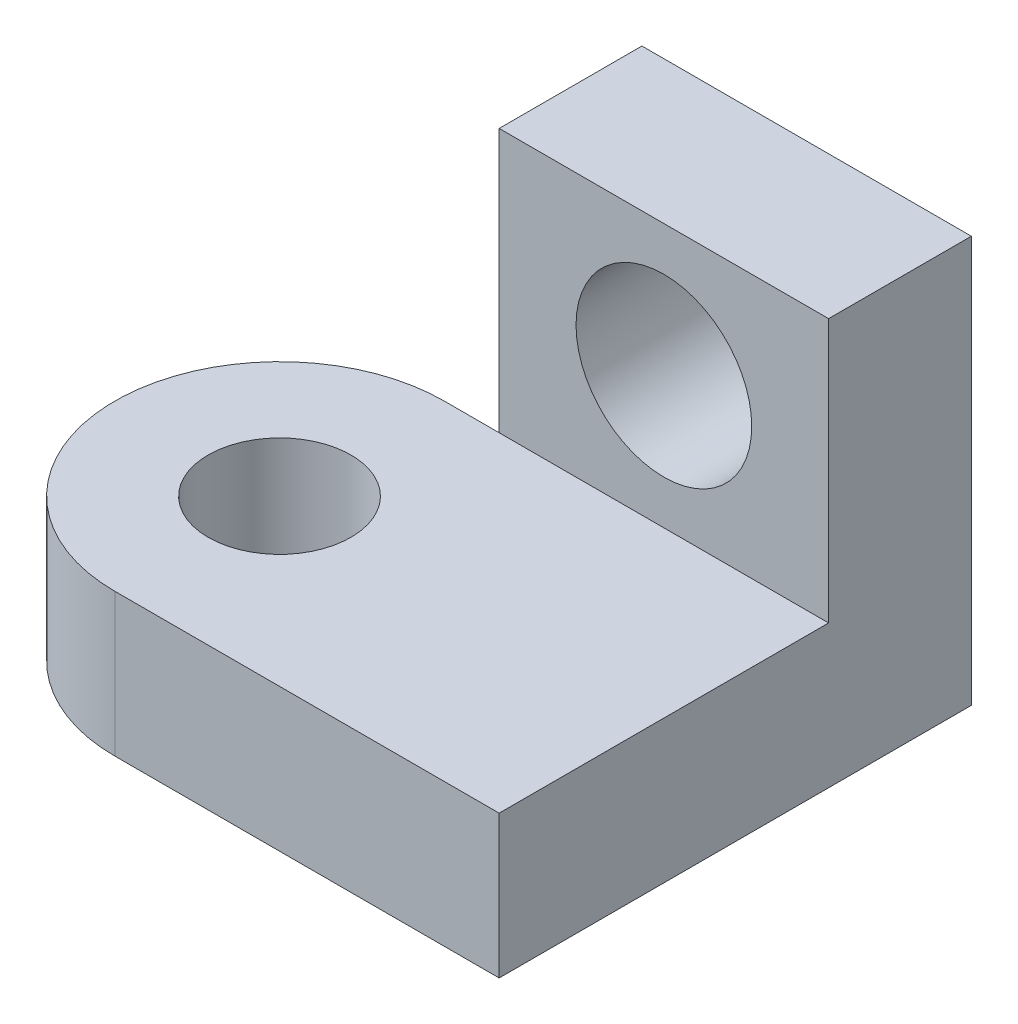
from build123d import *

# Parameters (mm, degrees)
SKETCH1_R           = 6.5
BOSS_EXTRUDE1_DEPTH = 13
SKETCH1_3_W         = 30
SKETCH1_3_H         = 13
BOSS_EXTRUDE2_DEPTH = 37
SKETCH2_R           = 8
CUT_EXTRUDE1_DEPTH  = 37


with BuildPart() as part:
    # Sketch1 → Boss-Extrude1 (new body)
    with BuildSketch(Plane(origin=(0, 0, 0), x_dir=(1, 0, 0), z_dir=(0, 1, 0))):
        with BuildLine():
            ThreePointArc((0, 30), (-15, 15), (0, 0))
            Line((0, 0), (35, 0))
            Line((35, 0), (35, 30))
            Line((35, 30), (0, 30))
        make_face()
        with Locations((0, 15)):
            Circle(SKETCH1_R, mode=Mode.SUBTRACT)
    extrude(amount=BOSS_EXTRUDE1_DEPTH)

    # Sketch1_3 → Boss-Extrude2 (add)
    with BuildSketch(Plane(origin=(0, 0, 0), x_dir=(1, 0, 0), z_dir=(0, 1, 0))):
        with Locations((20, 36.5)):
            Rectangle(SKETCH1_3_W, SKETCH1_3_H)
    extrude(amount=BOSS_EXTRUDE2_DEPTH)

    # Sketch2 → Cut-Extrude1 (cut)
    with BuildSketch(Plane.XY.offset(-30)):
        with Locations((20, 25)):
            Circle(SKETCH2_R)
    extrude(amount=-CUT_EXTRUDE1_DEPTH, mode=Mode.SUBTRACT)


solid = part.part
